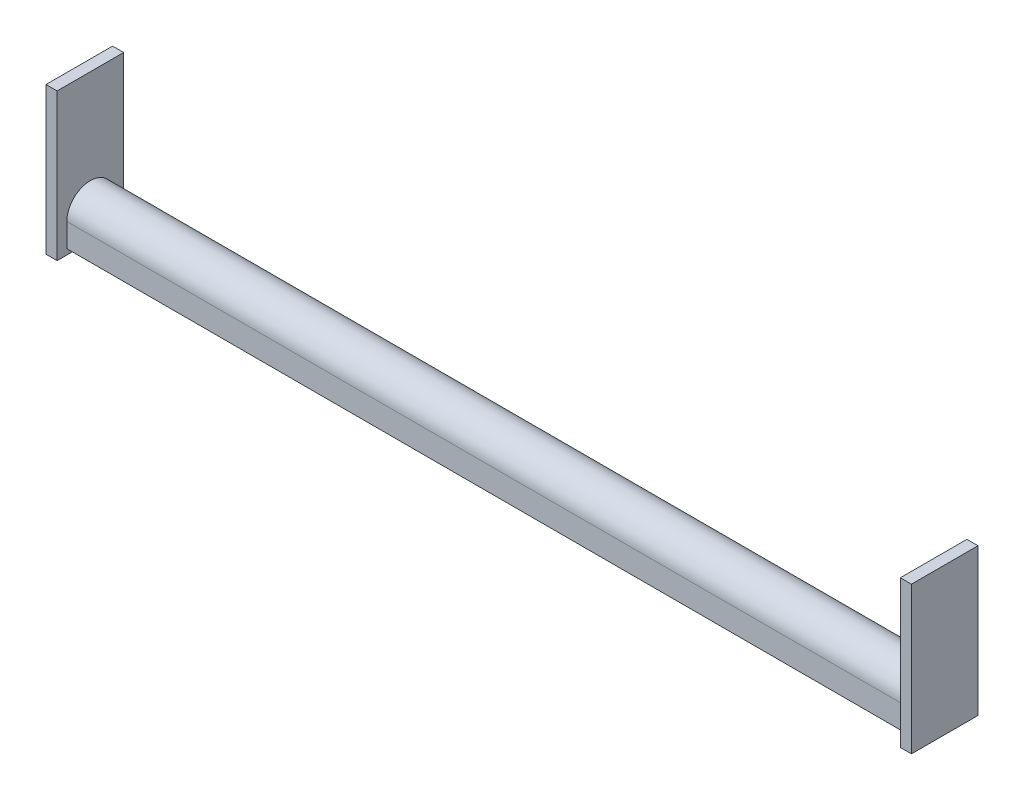
from build123d import *

# Parameters (mm, degrees)
SKETCH1_W           = 76.2
SKETCH1_H           = 168.275
BOSS_EXTRUDE1_DEPTH = 12.7
BOSS_EXTRUDE2_DEPTH = 965.2
SKETCH3_W           = 76.2
SKETCH3_H           = 168.275
BOSS_EXTRUDE3_DEPTH = 12.7


with BuildPart() as part:
    # Sketch1 → Boss-Extrude1 (new body)
    with BuildSketch(Plane(origin=(0, 0, 0), x_dir=(0, 0, -1), z_dir=(1, 0, 0))):
        Rectangle(SKETCH1_W, SKETCH1_H)
    extrude(amount=BOSS_EXTRUDE1_DEPTH)

    # Sketch2 → Boss-Extrude2 (add)
    with BuildSketch(Plane.ZY):
        with BuildLine():
            Line((-26.9875, -77.7875), (-26.9875, -50.8))
            ThreePointArc((-26.9875, -50.8), (0, -23.8125), (26.9875, -50.8))
            Line((26.9875, -50.8), (26.9875, -77.7875))
            Line((26.9875, -77.7875), (22.9235, -77.7875))
            Line((22.9235, -77.7875), (22.9235, -50.8))
            ThreePointArc((22.9235, -50.8), (0, -27.8765), (-22.9235, -50.8))
            Line((-22.9235, -50.8), (-22.9235, -77.7875))
            Line((-22.9235, -77.7875), (-26.9875, -77.7875))
        make_face()
    extrude(amount=BOSS_EXTRUDE2_DEPTH)

    # Sketch3 → Boss-Extrude3 (add)
    with BuildSketch(Plane.ZY.offset(965.2)):
        Rectangle(SKETCH3_W, SKETCH3_H)
    extrude(amount=BOSS_EXTRUDE3_DEPTH)


solid = part.part
